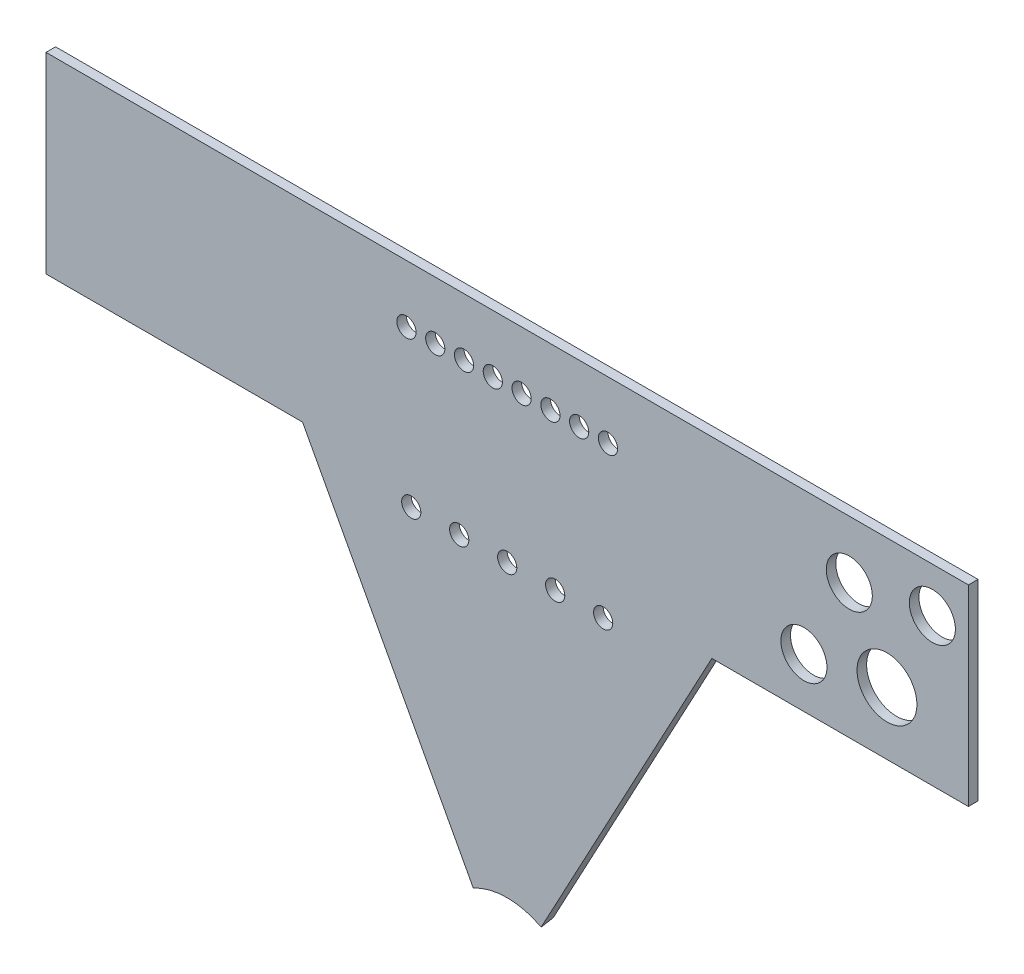
from build123d import *

# Parameters (mm, degrees)
BOSS_EXTRUDE1_DEPTH         = 3.175
BOSS_EXTRUDE1_DRAFT         = -28
CUT_EXTRUDE3_DEPTH          = 4.175
BOSS_EXTRUDE2_DEPTH         = 3.175
F_1_4_0_25_DIAMETER_HOLE1_D = 6.35
SKETCH9_R                   = 9.906
SKETCH9_R_2                 = 7.62
CUT_EXTRUDE4_DEPTH          = 4.175
F_1_4_0_25_DIAMETER_HOLE2_D = 6.35


with BuildPart() as part:
    # Sketch1 → Boss-Extrude1 (with draft: the straight prism first)
    with BuildSketch(Plane.XY):
        with BuildLine():
            Line((-101.780957474, 0), (-12.02943471, -167.25772623))
            ThreePointArc((-12.02943471, -167.25772623), (0, -164.234100952), (12.02943471, -167.25772623))
            Line((12.02943471, -167.25772623), (101.780957474, 0))
            Line((101.780957474, 0), (-101.780957474, 0))
        make_face()
    extrude(amount=BOSS_EXTRUDE1_DEPTH)
    # Boss-Extrude1: the draft: its side faces are tilted about the plane it starts from
    boss_extrude1_sides = [part.faces().sort_by_distance(p)[0] for p in [
        (56.905196092, -83.628863115, 1.5875),
        (0, 0, 1.5875),
        (-56.905196092, -83.628863115, 1.5875),
        (0, -164.234100952, 1.5875),
    ]]
    draft(boss_extrude1_sides, Plane.XY, BOSS_EXTRUDE1_DRAFT)

    # Sketch6 → Cut-Extrude3 (cut, through all)
    with BuildSketch(Plane.XY.offset(3.175)):
        Polygon((-103.696831485, 0), (-101.780957474, 0), (101.780957474, 0), (103.696831485, 0), (104.602717866, 1.688177446), (-104.602717866, 1.688177446), align=None)
        with BuildLine():
            Line((-11.231210531, -168.745268245), (-101.780957474, 0))
            Line((-101.780957474, 0), (-103.696831485, 0))
            Line((-103.696831485, 0), (-12.690350956, -169.596420612))
            ThreePointArc((-12.690350956, -169.596420612), (-11.968349556, -169.157869126), (-11.231210531, -168.745268245))
        make_face()
        with BuildLine():
            Line((103.696831485, 0), (101.780957474, 0))
            Line((101.780957474, 0), (11.231210531, -168.745268245))
            ThreePointArc((11.231210531, -168.745268245), (11.968349556, -169.157869126), (12.690350956, -169.596420612))
            Line((12.690350956, -169.596420612), (103.696831485, 0))
        make_face()
    extrude(amount=-CUT_EXTRUDE3_DEPTH, mode=Mode.SUBTRACT)

    # Sketch8 → Boss-Extrude2 (add)
    with BuildSketch(Plane.XY.offset(3.175)):
        Polygon((-101.780957474, 0), (-152.580957474, 0), (-152.580957474, -63.5), (-67.706467619, -63.5), align=None)
        Polygon((152.580957474, -63.5), (67.706467619, -63.5), (101.780957474, 0), (152.580957474, 0), align=None)
    extrude(amount=-BOSS_EXTRUDE2_DEPTH)

    # 1/4 (0.25) Diameter Hole1 (through all)
    with Locations(Plane.XY.offset(3.175)):
        with Locations((-33.3375, -19.05), (-23.8125, -19.05), (-14.2875, -19.05), (-4.7625, -19.05)):
            f_1_4_0_25_diameter_hole1 = Hole(F_1_4_0_25_DIAMETER_HOLE1_D / 2)

    # Mirror1: 1/4 (0.25) Diameter Hole1 across plane
    add(f_1_4_0_25_diameter_hole1.mirror(Plane(origin=(0, 0, 0), x_dir=(0, 0, 1), z_dir=(1, 0, 0))), mode=Mode.SUBTRACT)

    # Sketch9 → Cut-Extrude4 (cut, through all)
    with BuildSketch(Plane.XY.offset(3.175)):
        with Locations((125.639722953, -42.830834866)):
            Circle(SKETCH9_R)
        with Locations((140.652136328, -14.854238493)):
            Circle(SKETCH9_R_2)
        with Locations((113.178020253, -19.05)):
            Circle(SKETCH9_R_2)
        with Locations((98.165606878, -47.026596374)):
            Circle(SKETCH9_R_2)
    extrude(amount=-CUT_EXTRUDE4_DEPTH, mode=Mode.SUBTRACT)

    # 1/4 (0.25) Diameter Hole2 (through all)
    with Locations(Plane.XY.offset(3.175)):
        with Locations((-31.75, -69.85), (-15.875, -69.85), (0, -69.85), (15.875, -69.85), (31.75, -69.85)):
            Hole(F_1_4_0_25_DIAMETER_HOLE2_D / 2)


solid = part.part
